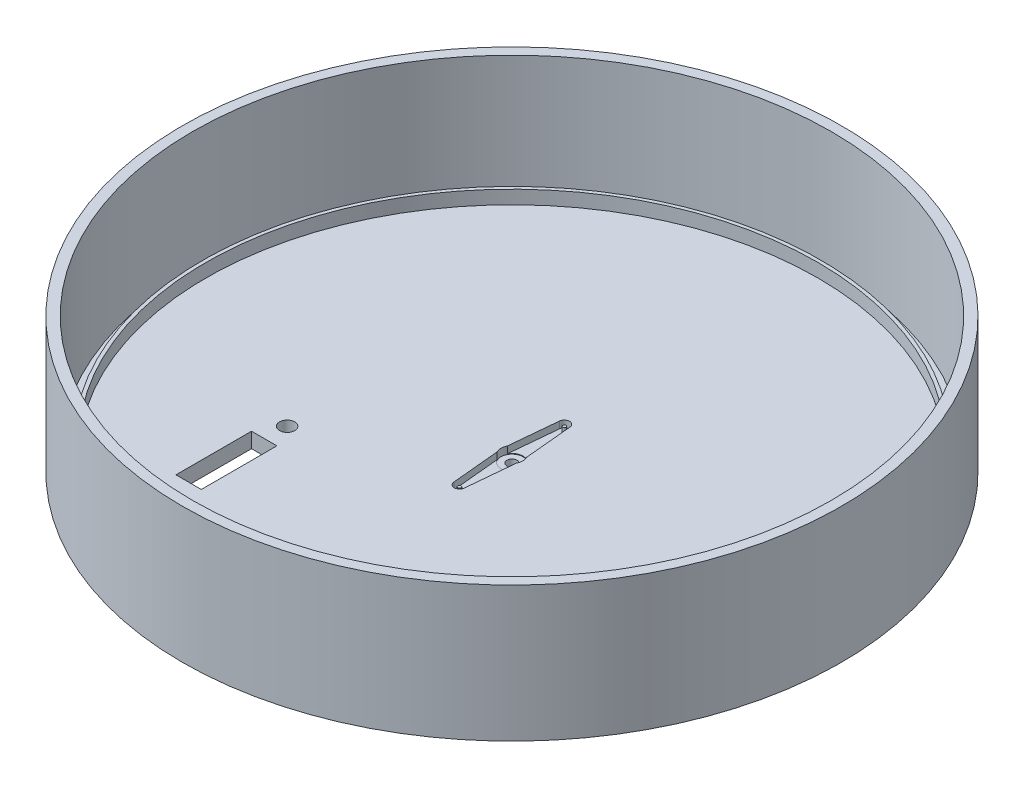
from build123d import *

# Parameters (mm, degrees)
SKETCH3_R                 = 97.5
BOSS_EXTRUDE3_DEPTH       = 40
SHELL4_T                  = -3
SHELL4_THICKNESS_2_FACE_R = 94.5
SHELL4_THICKNESS_2_DEPTH  = 1.5
CUT_EXTRUDE1_DEPTH        = 2
CUT_EXTRUDE2_REACH        = 145.571
SKETCH5_R                 = 1.5
SKETCH6_R                 = 3.25
CUT_EXTRUDE3_DEPTH        = 0.2
SKETCH7_R                 = 0.48
BOSS_EXTRUDE4_DEPTH       = 1.5
SKETCH8_R                 = 91.5
SKETCH8_R_2               = 90.5
BOSS_EXTRUDE5_DEPTH       = 4
CUT_EXTRUDE12_REACH       = 145.571
SKETCH9_R                 = 2.25
CUT_EXTRUDE13_REACH       = 145.571
SKETCH9_4_W               = 7.5
SKETCH9_4_H               = 22.36


with BuildPart() as part:
    # Sketch3 → Boss-Extrude3 (new body)
    with BuildSketch(Plane(origin=(0, 0, 0), x_dir=(1, 0, 0), z_dir=(0, 1, 0))):
        with Locations(Location((0, 0, 0), (0, 0, 270))):
            Circle(SKETCH3_R)
    extrude(amount=BOSS_EXTRUDE3_DEPTH)

    # Shell4
    shell4_openings = [part.faces().sort_by_distance(p)[0] for p in [
        (0, 40, 0),
    ]]
    offset(amount=SHELL4_T, openings=shell4_openings, kind=Kind.INTERSECTION)

    # Shell4 thickness 2 face (on inner face of the shell) → Shell4 thickness 2 (add)
    with BuildSketch(Plane(origin=(0, 3, 0), x_dir=(0, 0, -1), z_dir=(0, -1, 0))):
        Circle(SHELL4_THICKNESS_2_FACE_R)
    extrude(amount=-SHELL4_THICKNESS_2_DEPTH)

    # Sketch4 → Cut-Extrude1 (cut)
    with BuildSketch(Plane(origin=(0, 4.5, 0), x_dir=(1, 0, 0), z_dir=(0, 1, 0))):
        with BuildLine():
            Line((2.869908719, 1.525163579), (1.543202838, 15.645))
            ThreePointArc((1.543202838, 15.645), (0, 17.05), (-1.543202838, 15.645))
            Line((-1.543202838, 15.645), (-2.869908719, 1.525163579))
            ThreePointArc((-2.869908719, 1.525163579), (-3.25, 0), (-2.869908719, -1.525163579))
            Line((-2.869908719, -1.525163579), (-1.543202838, -15.645))
            ThreePointArc((-1.543202838, -15.645), (0, -17.05), (1.543202838, -15.645))
            Line((1.543202838, -15.645), (2.869908719, -1.525163579))
            ThreePointArc((2.869908719, -1.525163579), (3.25, 0), (2.869908719, 1.525163579))
        make_face()
    extrude(amount=-CUT_EXTRUDE1_DEPTH, mode=Mode.SUBTRACT)

    # Sketch5 → Cut-Extrude2 (cut, up to next)
    with BuildSketch(Plane.XZ, mode=Mode.PRIVATE) as cut_extrude2_sk1:
        with Locations(Location((0, 0, 0), (0, 0, 270))):
            Circle(SKETCH5_R)
    cut_extrude2_tool1 = extrude(cut_extrude2_sk1.sketch, amount=-CUT_EXTRUDE2_REACH, mode=Mode.PRIVATE) & part.part
    add(cut_extrude2_tool1.solids().sort_by_distance((0, 0, 0))[0], mode=Mode.SUBTRACT)

    # Sketch6 → Cut-Extrude3 (cut)
    with BuildSketch(Plane(origin=(0, 2.5, 0), x_dir=(1, 0, 0), z_dir=(0, 1, 0))):
        with Locations(Location((0, 0, 0), (0, 0, 270))):
            Circle(SKETCH6_R)
    extrude(amount=-CUT_EXTRUDE3_DEPTH, mode=Mode.SUBTRACT)

    # Sketch7 → Boss-Extrude4 (add)
    with BuildSketch(Plane(origin=(0, 2.5, 0), x_dir=(1, 0, 0), z_dir=(0, 1, 0))):
        with Locations(Location((0, 15.5, 0), (0, 0, 270))):
            Circle(SKETCH7_R)
        with Locations(Location((0, -15.5, 0), (0, 0, 270))):
            Circle(SKETCH7_R)
    extrude(amount=BOSS_EXTRUDE4_DEPTH)

    # Sketch8 → Boss-Extrude5 (add)
    with BuildSketch(Plane(origin=(0, 4.5, 0), x_dir=(1, 0, 0), z_dir=(0, 1, 0))):
        with Locations(Location((0, 0, 0), (0, 0, 270))):
            Circle(SKETCH8_R)
        with Locations(Location((0, 0, 0), (0, 0, 270))):
            Circle(SKETCH8_R_2, mode=Mode.SUBTRACT)
    extrude(amount=BOSS_EXTRUDE5_DEPTH)

    # Sketch9 → Cut-Extrude12 (cut, up to next)
    with BuildSketch(Plane.XZ, mode=Mode.PRIVATE) as cut_extrude12_sk1:
        with Locations(Location((40.5, 26, 0), (0, 0, 270))):
            Circle(SKETCH9_R)
    cut_extrude12_tool1 = extrude(cut_extrude12_sk1.sketch, amount=-CUT_EXTRUDE12_REACH, mode=Mode.PRIVATE) & part.part
    # Sketch9 → Cut-Extrude12 (cut, up to next)
    with BuildSketch(Plane.XZ, mode=Mode.PRIVATE) as cut_extrude12_sk2:
        with Locations(Location((40.5, 64, 0), (0, 0, 90))):
            Circle(SKETCH9_R)
    cut_extrude12_tool2 = extrude(cut_extrude12_sk2.sketch, amount=-CUT_EXTRUDE12_REACH, mode=Mode.PRIVATE) & part.part
    # Sketch9 → Cut-Extrude12 (cut, up to next)
    with BuildSketch(Plane.XZ, mode=Mode.PRIVATE) as cut_extrude12_sk3:
        with Locations(Location((-40.5, 64, 0), (0, 0, 270))):
            Circle(SKETCH9_R)
    cut_extrude12_tool3 = extrude(cut_extrude12_sk3.sketch, amount=-CUT_EXTRUDE12_REACH, mode=Mode.PRIVATE) & part.part
    # Sketch9 → Cut-Extrude12 (cut, up to next)
    with BuildSketch(Plane.XZ, mode=Mode.PRIVATE) as cut_extrude12_sk4:
        with Locations(Location((-40.5, 26, 0), (0, 0, 90))):
            Circle(SKETCH9_R)
    cut_extrude12_tool4 = extrude(cut_extrude12_sk4.sketch, amount=-CUT_EXTRUDE12_REACH, mode=Mode.PRIVATE) & part.part
    add(cut_extrude12_tool1.solids().sort_by_distance((40.5, 0, 26))[0], mode=Mode.SUBTRACT)
    add(cut_extrude12_tool2.solids().sort_by_distance((40.5, 0, 64))[0], mode=Mode.SUBTRACT)
    add(cut_extrude12_tool3.solids().sort_by_distance((-40.5, 0, 64))[0], mode=Mode.SUBTRACT)
    add(cut_extrude12_tool4.solids().sort_by_distance((-40.5, 0, 26))[0], mode=Mode.SUBTRACT)

    # Sketch9_4 → Cut-Extrude13 (cut, up to next)
    with BuildSketch(Plane.XZ, mode=Mode.PRIVATE) as cut_extrude13_sk1:
        with Locations((40.75, 43.717267505)):
            Rectangle(SKETCH9_4_W, SKETCH9_4_H)
    cut_extrude13_tool1 = extrude(cut_extrude13_sk1.sketch, amount=-CUT_EXTRUDE13_REACH, mode=Mode.PRIVATE) & part.part
    # Sketch9_4 → Cut-Extrude13 (cut, up to next)
    with BuildSketch(Plane.XZ, mode=Mode.PRIVATE) as cut_extrude13_sk2:
        with Locations((-40.75, 43.717267505)):
            Rectangle(SKETCH9_4_W, SKETCH9_4_H)
    cut_extrude13_tool2 = extrude(cut_extrude13_sk2.sketch, amount=-CUT_EXTRUDE13_REACH, mode=Mode.PRIVATE) & part.part
    add(cut_extrude13_tool1.solids().sort_by_distance((40.75, 0, 43.717268))[0], mode=Mode.SUBTRACT)
    add(cut_extrude13_tool2.solids().sort_by_distance((-40.75, 0, 43.717268))[0], mode=Mode.SUBTRACT)


solid = part.part
